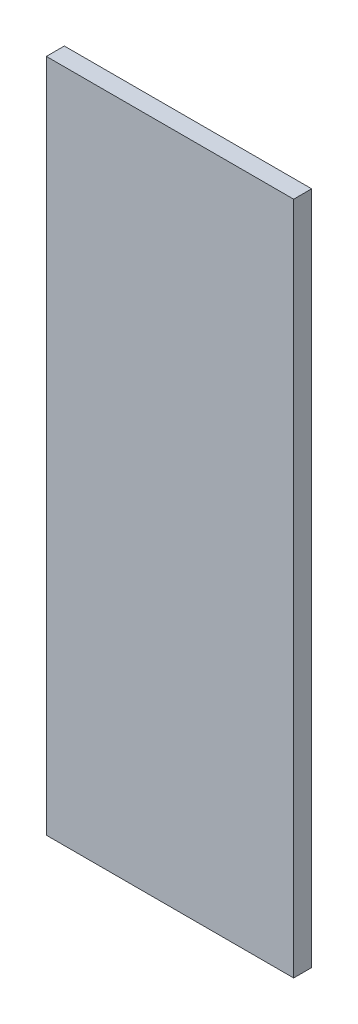
from build123d import *

# Parameters (mm, degrees)
SKETCH1_W           = 55
SKETCH1_H           = 150
BOSS_EXTRUDE1_DEPTH = 4


with BuildPart() as part:
    # Sketch1 → Boss-Extrude1 (new body)
    with BuildSketch(Plane.XY):
        with Locations((27.5, 75)):
            Rectangle(SKETCH1_W, SKETCH1_H)
    extrude(amount=BOSS_EXTRUDE1_DEPTH)


solid = part.part
